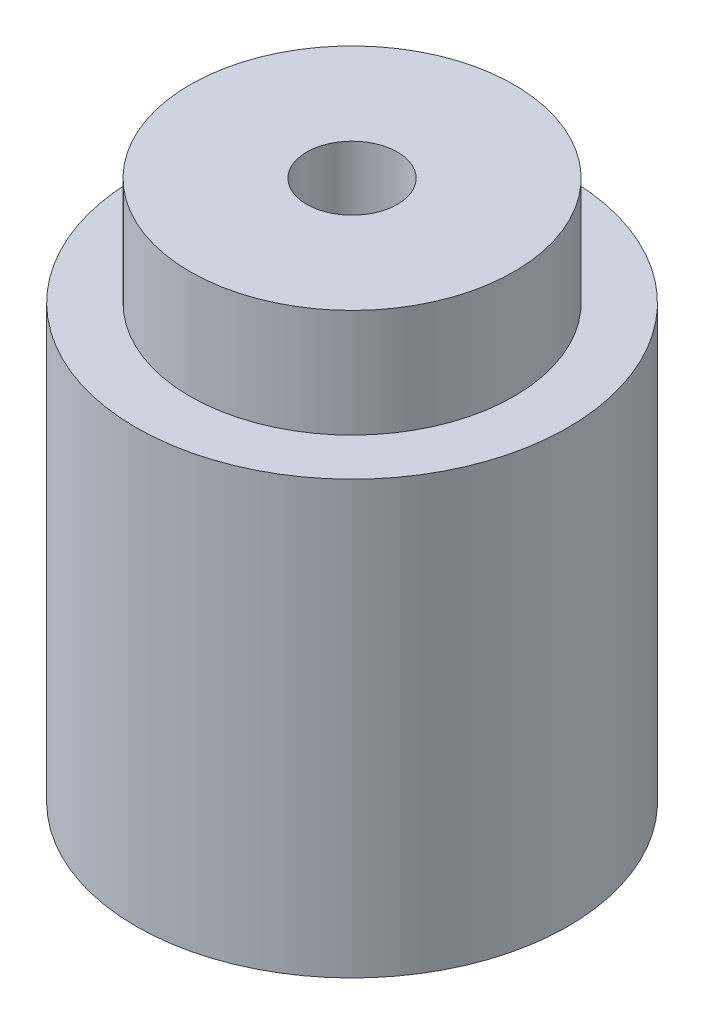
from build123d import *

# Parameters (mm, degrees)
SKETCH1_R             = 10
BOSS_EXTRUDE1_DEPTH   = 25
M5_TAPPED_HOLE1_D     = 4.2
M5_TAPPED_HOLE1_DEPTH = 13.7381927
M5_TAPPED_HOLE1_TIP   = 1.2618073
SKETCH18_R            = 10
SKETCH18_R_2          = 7.5
CUT_EXTRUDE1_DEPTH    = 5


with BuildPart() as part:
    # Sketch1 → Boss-Extrude1 (new body)
    with BuildSketch(Plane(origin=(0, 0, 0), x_dir=(1, 0, 0), z_dir=(0, 1, 0))):
        Circle(SKETCH1_R)
    extrude(amount=BOSS_EXTRUDE1_DEPTH)

    # M5 Tapped Hole1
    with Locations(Plane(origin=(0, 25, 0), x_dir=(1, 0, 0), z_dir=(0, 1, 0))):
        with Locations((0, 0)):
            Hole(M5_TAPPED_HOLE1_D / 2, depth=M5_TAPPED_HOLE1_DEPTH)
            with Locations((0, 0, -(M5_TAPPED_HOLE1_DEPTH + M5_TAPPED_HOLE1_TIP / 2))):  # 118° drill point
                Cone(0, M5_TAPPED_HOLE1_D / 2, M5_TAPPED_HOLE1_TIP, mode=Mode.SUBTRACT)

    # Sketch18 → Cut-Extrude1 (cut)
    with BuildSketch(Plane(origin=(0, 25, 0), x_dir=(1, 0, 0), z_dir=(0, 1, 0))):
        Circle(SKETCH18_R)
        Circle(SKETCH18_R_2, mode=Mode.SUBTRACT)
    extrude(amount=-CUT_EXTRUDE1_DEPTH, mode=Mode.SUBTRACT)


solid = part.part
